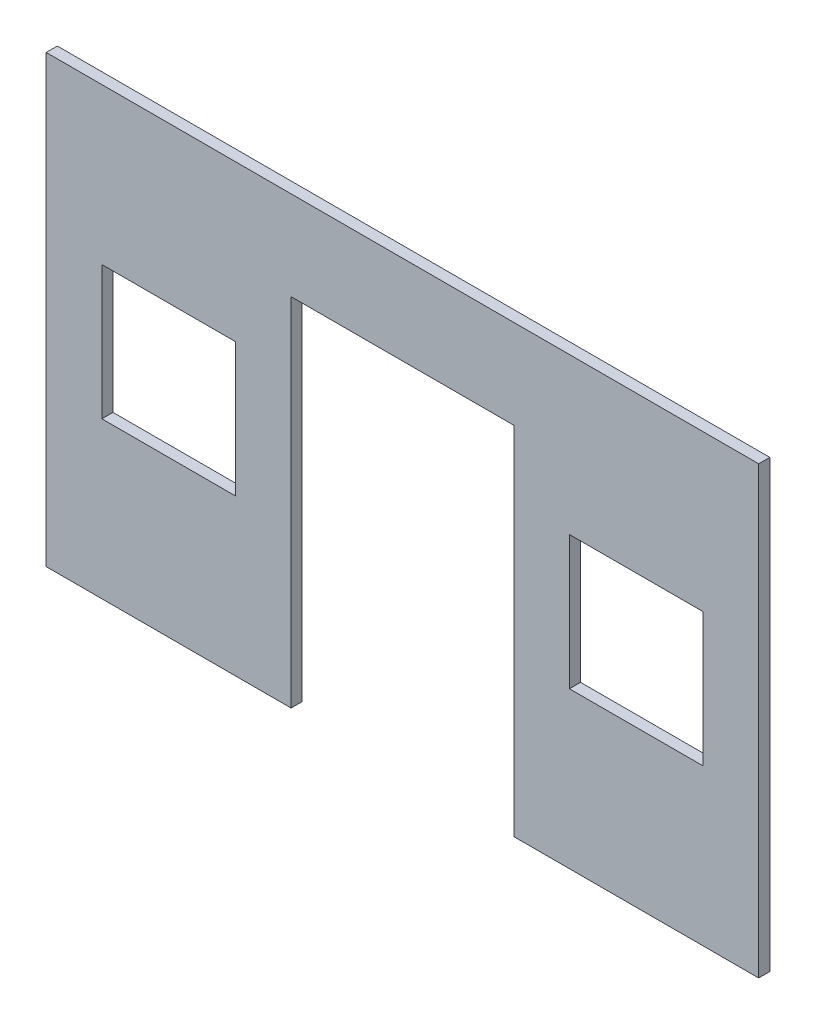
from build123d import *

# Parameters (mm, degrees)
SKETCH1_W           = 406.4
SKETCH1_H           = 254
BOSS_EXTRUDE1_DEPTH = 6.35
CUT_EXTRUDE1_REACH  = 8.35
SKETCH2_W           = 127
SKETCH2_H           = 203.2
CUT_EXTRUDE3_REACH  = 8.35
SKETCH3_W           = 76.2
SKETCH3_H           = 76.2
CUT_EXTRUDE4_REACH  = 8.35
SKETCH4_W           = 76.2
SKETCH4_H           = 76.2


with BuildPart() as part:
    # Sketch1 → Boss-Extrude1 (new body)
    with BuildSketch(Plane.XY):
        with Locations((0, 127)):
            Rectangle(SKETCH1_W, SKETCH1_H)
    extrude(amount=BOSS_EXTRUDE1_DEPTH)

    # Sketch2 → Cut-Extrude1 (cut, up to next)
    with BuildSketch(Plane.XY.offset(6.35), mode=Mode.PRIVATE) as cut_extrude1_sk1:
        with Locations((0, 101.6)):
            Rectangle(SKETCH2_W, SKETCH2_H)
    cut_extrude1_tool1 = extrude(cut_extrude1_sk1.sketch, amount=-CUT_EXTRUDE1_REACH, mode=Mode.PRIVATE) & part.part
    add(cut_extrude1_tool1.solids().sort_by_distance((0, 101.6, 6.35))[0], mode=Mode.SUBTRACT)

    # Sketch3 → Cut-Extrude3 (cut, up to next)
    with BuildSketch(Plane.XY.offset(6.35), mode=Mode.PRIVATE) as cut_extrude3_sk1:
        with Locations((-133.35, 127)):
            Rectangle(SKETCH3_W, SKETCH3_H)
    cut_extrude3_tool1 = extrude(cut_extrude3_sk1.sketch, amount=-CUT_EXTRUDE3_REACH, mode=Mode.PRIVATE) & part.part
    add(cut_extrude3_tool1.solids().sort_by_distance((-133.35, 127, 6.35))[0], mode=Mode.SUBTRACT)

    # Sketch4 → Cut-Extrude4 (cut, up to next)
    with BuildSketch(Plane.XY.offset(6.35), mode=Mode.PRIVATE) as cut_extrude4_sk1:
        with Locations((133.35, 127)):
            Rectangle(SKETCH4_W, SKETCH4_H)
    cut_extrude4_tool1 = extrude(cut_extrude4_sk1.sketch, amount=-CUT_EXTRUDE4_REACH, mode=Mode.PRIVATE) & part.part
    add(cut_extrude4_tool1.solids().sort_by_distance((133.35, 127, 6.35))[0], mode=Mode.SUBTRACT)


solid = part.part
